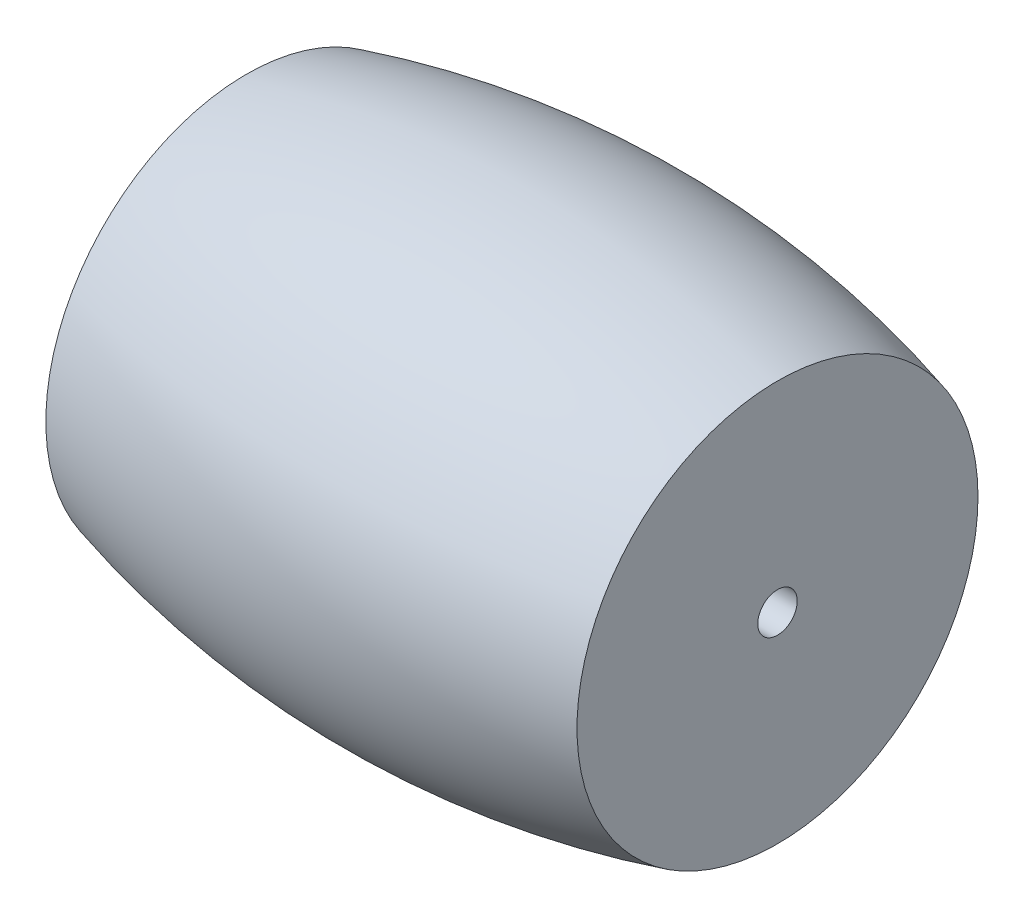
from build123d import *


with BuildPart() as part:
    # Sketch2 → Revolve1 (revolve)
    with BuildSketch(Plane.XY):
        with BuildLine():
            Line((-16.823237932, 12.7), (-16.823237932, 1.25))
            Line((-16.823237932, 1.25), (16.823237932, 1.25))
            Line((16.823237932, 1.25), (16.823237932, 12.7))
            ThreePointArc((16.823237932, 12.7), (0, 14.972301916), (-16.823237932, 12.7))
        make_face()
    revolve(axis=Axis((27.966961403, 0, 0), (-1, 0, 0)))


solid = part.part
